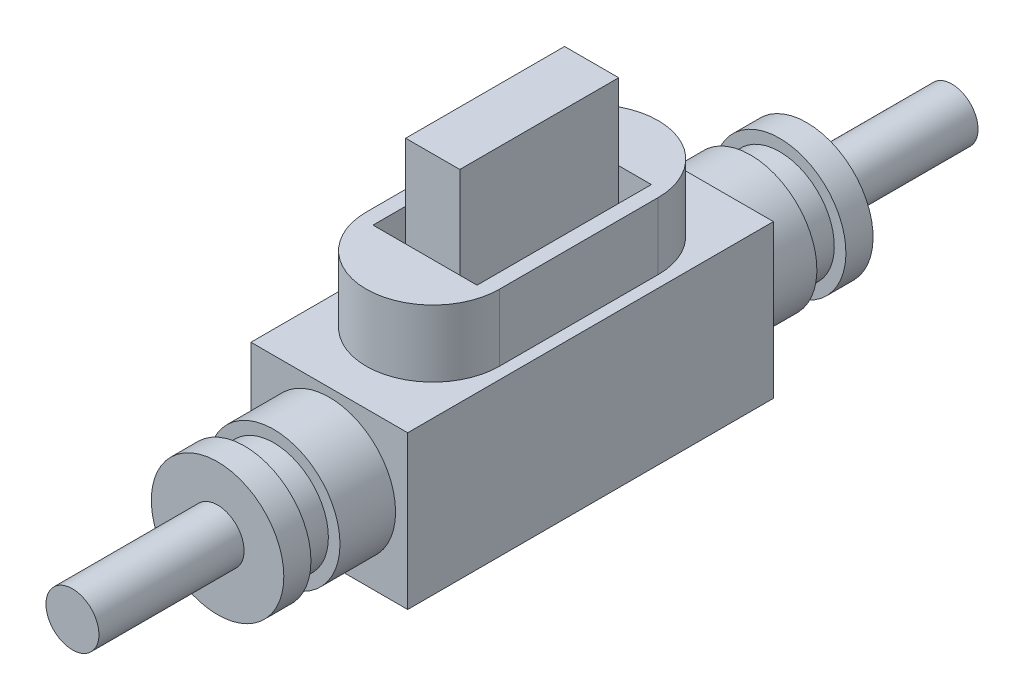
from build123d import *

# Parameters (mm, degrees)
SKETCH1_W           = 10.8
SKETCH1_H           = 25.2
BOSS_EXTRUDE1_DEPTH = 10.55
SKETCH2_R           = 4.565
BOSS_EXTRUDE2_DEPTH = 7.7
SKETCH3_R           = 4.565
BOSS_EXTRUDE3_DEPTH = 7.7
SKETCH4_W           = 2
SKETCH4_H           = 0.8
SKETCH5_W           = 2
SKETCH5_H           = 0.8
BOSS_EXTRUDE4_DEPTH = 4.6
SKETCH7_W           = 7.17
SKETCH7_H           = 12.01
CUT_EXTRUDE1_DEPTH  = 3.6
SKETCH8_W           = 3.73
SKETCH8_H           = 10.95
BOSS_EXTRUDE5_DEPTH = 9.38
SKETCH9_R           = 1.8
BOSS_EXTRUDE6_DEPTH = 10
SKETCH11_R          = 1.825
BOSS_EXTRUDE7_DEPTH = 10


with BuildPart() as part:
    # Sketch1 → Boss-Extrude1 (new body)
    with BuildSketch(Plane(origin=(0, 0, 0), x_dir=(1, 0, 0), z_dir=(0, 1, 0))):
        Rectangle(SKETCH1_W, SKETCH1_H)
    extrude(amount=BOSS_EXTRUDE1_DEPTH)

    # Sketch2 → Boss-Extrude2 (add)
    with BuildSketch(Plane.XY.offset(12.6)):
        with Locations((0, 5.403958649)):
            Circle(SKETCH2_R)
    extrude(amount=BOSS_EXTRUDE2_DEPTH)

    # Sketch3 → Boss-Extrude3 (add)
    with BuildSketch(Plane(origin=(0, 0, -12.6), x_dir=(-1, 0, 0), z_dir=(0, 0, -1))):
        with Locations((0, 5.344439272)):
            Circle(SKETCH3_R)
    extrude(amount=BOSS_EXTRUDE3_DEPTH)

    # Sketch4 → Cut-Revolve1 (revolve, cut)
    with BuildSketch(Plane(origin=(0, 0, 0), x_dir=(0, 0, -1), z_dir=(1, 0, 0))):
        with Locations((-17.43, 9.568958649)):
            Rectangle(SKETCH4_W, SKETCH4_H)
    revolve(axis=Axis((0, 5.403958649, 20.3), (0, 0, -1)), mode=Mode.SUBTRACT)

    # Sketch5 → Cut-Revolve2 (revolve, cut)
    with BuildSketch(Plane(origin=(0, 0, 0), x_dir=(0, 0, -1), z_dir=(1, 0, 0))):
        with Locations((17.43, 9.509439272)):
            Rectangle(SKETCH5_W, SKETCH5_H)
    revolve(axis=Axis((0, 5.344439272, -20.3), (0, 0, 1)), mode=Mode.SUBTRACT)

    # Sketch6 → Boss-Extrude4 (add)
    with BuildSketch(Plane(origin=(0, 10.55, 0), x_dir=(1, 0, 0), z_dir=(0, 1, 0))):
        with BuildLine():
            Line((4.595, -5.465), (4.595, 5.465))
            ThreePointArc((4.595, 5.465), (0, 10.06), (-4.595, 5.465))
            Line((-4.595, 5.465), (-4.595, -5.465))
            ThreePointArc((-4.595, -5.465), (0, -10.06), (4.595, -5.465))
        make_face()
    extrude(amount=BOSS_EXTRUDE4_DEPTH)

    # Sketch7 → Cut-Extrude1 (cut)
    with BuildSketch(Plane(origin=(0, 15.15, 0), x_dir=(1, 0, 0), z_dir=(0, 1, 0))):
        Rectangle(SKETCH7_W, SKETCH7_H)
    extrude(amount=-CUT_EXTRUDE1_DEPTH, mode=Mode.SUBTRACT)

    # Sketch8 → Boss-Extrude5 (add)
    with BuildSketch(Plane(origin=(0, 11.55, 0), x_dir=(1, 0, 0), z_dir=(0, 1, 0))):
        Rectangle(SKETCH8_W, SKETCH8_H)
    extrude(amount=BOSS_EXTRUDE5_DEPTH)

    # Sketch9 → Boss-Extrude6 (add)
    with BuildSketch(Plane(origin=(0, 0, -20.3), x_dir=(-1, 0, 0), z_dir=(0, 0, -1))):
        with Locations((0, 5.407254025)):
            Circle(SKETCH9_R)
    extrude(amount=BOSS_EXTRUDE6_DEPTH)

    # Sketch11 → Boss-Extrude7 (add)
    with BuildSketch(Plane.XY.offset(20.3)):
        with Locations((0, 5.564693588)):
            Circle(SKETCH11_R)
    extrude(amount=BOSS_EXTRUDE7_DEPTH)


solid = part.part
